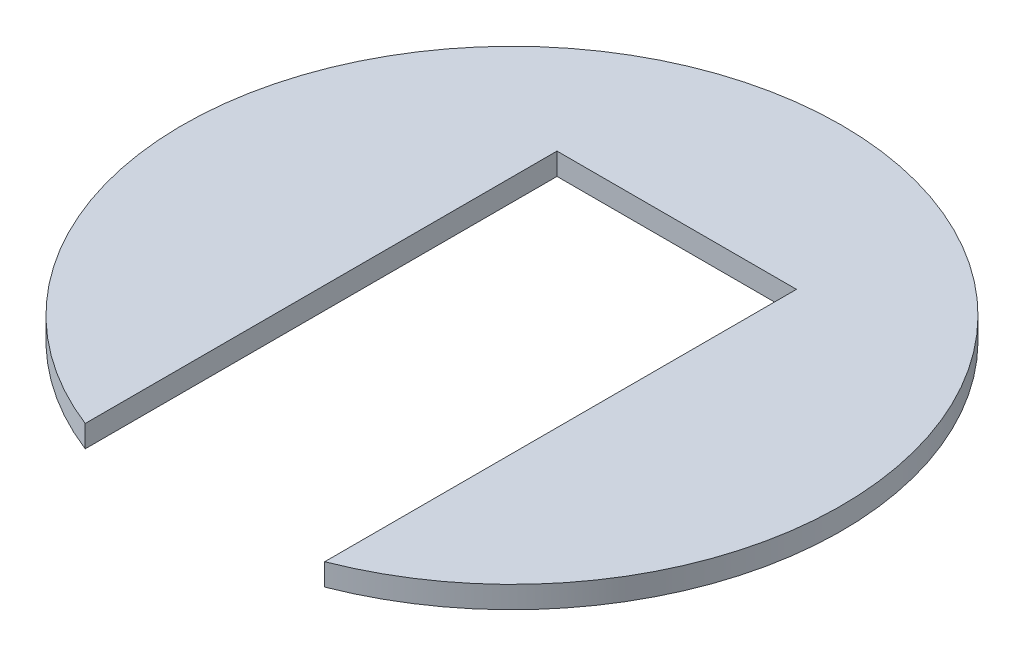
from build123d import *

# Parameters (mm, degrees)
EXTRUDE1_DEPTH = 10


with BuildPart() as part:
    # Sketch1 → Extrude1 (new body)
    with BuildSketch(Plane(origin=(0, 0, 0), x_dir=(1, 0, 0), z_dir=(0, 1, 0))):
        with BuildLine():
            Line((-54.5, -139.748881928), (-54.5, 75))
            Line((-54.5, 75), (54.5, 75))
            Line((54.5, 75), (54.5, -139.748881928))
            ThreePointArc((54.5, -139.748881928), (0, 150), (-54.5, -139.748881928))
        make_face()
    extrude(amount=EXTRUDE1_DEPTH)


solid = part.part
